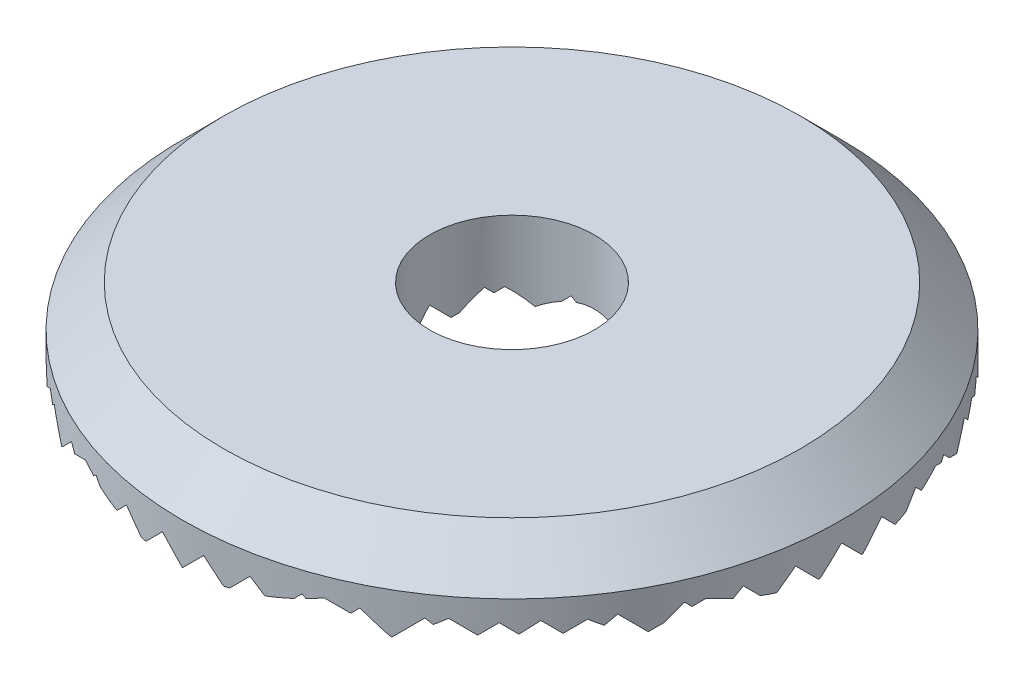
from build123d import *

# Parameters (mm, degrees)
SKETCH1_R               = 8
SKETCH1_R_2             = 2
BOSS_EXTRUDE1_DEPTH     = 2
CHAMFER1_SIZE           = 1
CUT_EXTRUDE2_DEPTH      = 9
CUT_EXTRUDE2_DEPTH_BACK = 9
CUT_EXTRUDE4_DEPTH      = 9
CUT_EXTRUDE4_DEPTH_BACK = 9


with BuildPart() as part:
    # Sketch1 → Boss-Extrude1 (new body)
    with BuildSketch(Plane(origin=(0, 0, 0), x_dir=(1, 0, 0), z_dir=(0, 1, 0))):
        Circle(SKETCH1_R)
        Circle(SKETCH1_R_2, mode=Mode.SUBTRACT)
    extrude(amount=BOSS_EXTRUDE1_DEPTH)

    # Chamfer1
    chamfer1_edges = [part.edges().sort_by_distance(p)[0] for p in [
        (-8, 2, 0),
    ]]
    chamfer(chamfer1_edges, length=CHAMFER1_SIZE)

    # Sketch2 → Cut-Extrude2 (cut, two sides)
    with BuildSketch(Plane.XY) as cut_extrude2_sk:
        Polygon((-7.5, 0.5), (-8, 0), (-7, 0), align=None)
        Polygon((-6.5, 0.5), (-7, 0), (-6, 0), align=None)
        Polygon((-5.5, 0.5), (-6, 0), (-5, 0), align=None)
        Polygon((-4.5, 0.5), (-5, 0), (-4, 0), align=None)
        Polygon((-3.5, 0.5), (-4, 0), (-3, 0), align=None)
        Polygon((-2.5, 0.5), (-3, 0), (-2, 0), align=None)
        Polygon((-1.5, 0.5), (-2, 0), (-1, 0), align=None)
        Polygon((-0.5, 0.5), (-1, 0), (0, 0), align=None)
        Polygon((0.5, 0.5), (0, 0), (1, 0), align=None)
        Polygon((1.5, 0.5), (1, 0), (2, 0), align=None)
        Polygon((2.5, 0.5), (2, 0), (3, 0), align=None)
        Polygon((3.5, 0.5), (3, 0), (4, 0), align=None)
        Polygon((4.5, 0.5), (4, 0), (5, 0), align=None)
        Polygon((5.5, 0.5), (5, 0), (6, 0), align=None)
        Polygon((6.5, 0.5), (6, 0), (7, 0), align=None)
        Polygon((7.5, 0.5), (7, 0), (8, 0), align=None)
    extrude(amount=CUT_EXTRUDE2_DEPTH, mode=Mode.SUBTRACT)
    extrude(cut_extrude2_sk.sketch, amount=-CUT_EXTRUDE2_DEPTH_BACK, mode=Mode.SUBTRACT)

    # Sketch3 → Cut-Extrude4 (cut, two sides)
    with BuildSketch(Plane(origin=(0, 0, 0), x_dir=(0, 0, -1), z_dir=(1, 0, 0))) as cut_extrude4_sk:
        Polygon((7.171423252, 0.502310297), (6.669112955, 0), (8, 0), align=None)
        Polygon((6.163993671, 0.505119284), (5.658874386, 0), (6.669112955, 0), align=None)
        Polygon((5.150930406, 0.50794398), (4.642986426, 0), (5.658874386, 0), align=None)
        Polygon((4.132201954, 0.510784472), (3.621417482, 0), (4.642986426, 0), align=None)
        Polygon((3.107776635, 0.513640848), (2.594135787, 0), (3.621417482, 0), align=None)
        Polygon((1.041707783, 0.519401609), (0.522306174, 0), (1.561109392, 0), align=None)
        Polygon((2.077622589, 0.516513197), (1.561109392, 0), (2.594135787, 0), align=None)
        Polygon((0, 0.522306174), (-0.522306174, 0), (0.522306174, 0), align=None)
        Polygon((-1.047533154, 0.525226981), (-1.572760135, 0), (-0.522306174, 0), align=None)
        Polygon((-2.100924256, 0.528164121), (-2.629088377, 0), (-1.572760135, 0), align=None)
        Polygon((-3.160206064, 0.531117687), (-3.69132375, 0), (-2.629088377, 0), align=None)
        Polygon((-4.225411519, 0.534087769), (-4.759499288, 0), (-3.69132375, 0), align=None)
        Polygon((-5.296573748, 0.53707446), (-5.833648209, 0), (-4.759499288, 0), align=None)
        Polygon((-6.373726062, 0.540077854), (-6.913803916, 0), (-5.833648209, 0), align=None)
        Polygon((-7.456901958, 0.543098042), (-8, 0), (-6.913803916, 0), align=None)
    extrude(amount=CUT_EXTRUDE4_DEPTH, mode=Mode.SUBTRACT)
    extrude(cut_extrude4_sk.sketch, amount=-CUT_EXTRUDE4_DEPTH_BACK, mode=Mode.SUBTRACT)


solid = part.part
